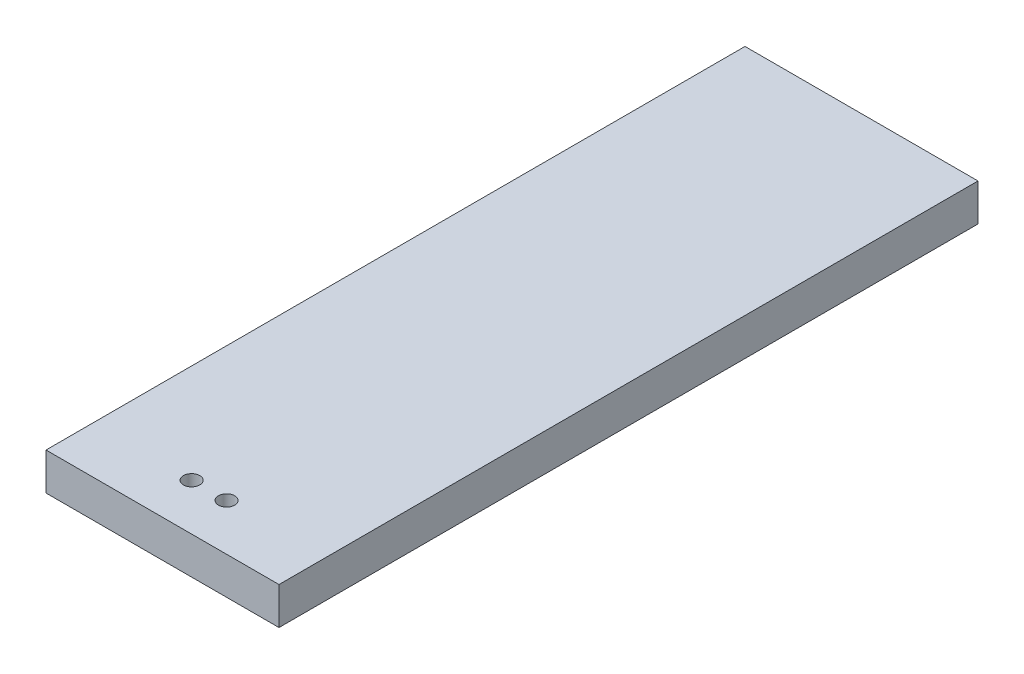
from build123d import *

# Parameters (mm, degrees)
SKETCH1_W           = 10
SKETCH1_H           = 30
BOSS_EXTRUDE1_DEPTH = 1.6
SKETCH3_R           = 0.35
CUT_EXTRUDE1_DEPTH  = 2.6


with BuildPart() as part:
    # Sketch1 → Boss-Extrude1 (new body)
    with BuildSketch(Plane(origin=(0, 0, 0), x_dir=(1, 0, 0), z_dir=(0, 1, 0))):
        with Locations((5, 15)):
            Rectangle(SKETCH1_W, SKETCH1_H)
    extrude(amount=BOSS_EXTRUDE1_DEPTH)

    # Sketch3 → Cut-Extrude1 (cut, through all)
    with BuildSketch(Plane(origin=(0, 1.6, 0), x_dir=(1, 0, 0), z_dir=(0, 1, 0))):
        with Locations((4.25, 2)):
            Circle(SKETCH3_R)
        with Locations((5.75, 2)):
            Circle(SKETCH3_R)
    extrude(amount=-CUT_EXTRUDE1_DEPTH, mode=Mode.SUBTRACT)


solid = part.part
